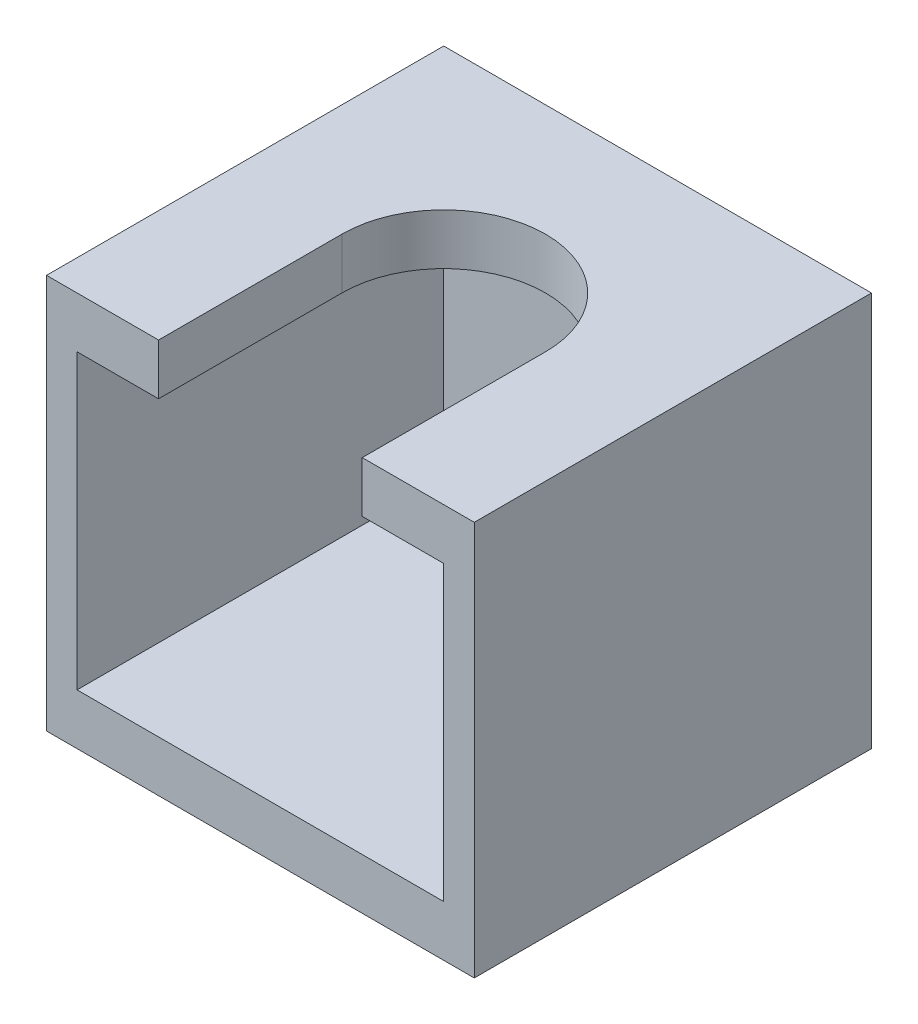
from build123d import *

# Parameters (mm, degrees)
BOSS_EXTRUDE1_DEPTH = 11.5
SKETCH2_W           = 16.8
SKETCH2_H           = 15.6
BOSS_EXTRUDE2_DEPTH = 2
BOSS_EXTRUDE3_DEPTH = 2


with BuildPart() as part:
    # Sketch1 → Boss-Extrude1 (new body)
    with BuildSketch(Plane(origin=(0, 0, 0), x_dir=(1, 0, 0), z_dir=(0, 1, 0))):
        Polygon((-8.4, 8.4), (-8.4, -7.2), (-7.2, -7.2), (-7.2, 7.2), (7.2, 7.2), (7.2, -7.2), (8.4, -7.2), (8.4, 8.4), align=None)
    extrude(amount=BOSS_EXTRUDE1_DEPTH)

    # Sketch2 → Boss-Extrude2 (add)
    with BuildSketch(Plane.XZ):
        with Locations((0, -0.6)):
            Rectangle(SKETCH2_W, SKETCH2_H)
    extrude(amount=BOSS_EXTRUDE2_DEPTH)

    # Sketch3 → Boss-Extrude3 (add)
    with BuildSketch(Plane(origin=(0, 11.5, 0), x_dir=(1, 0, 0), z_dir=(0, 1, 0))):
        with BuildLine():
            Line((-4, 0), (-4, -7.2))
            Line((-4, -7.2), (-8.4, -7.2))
            Line((-8.4, -7.2), (-8.4, 8.4))
            Line((-8.4, 8.4), (8.4, 8.4))
            Line((8.4, 8.4), (8.4, -7.2))
            Line((8.4, -7.2), (4, -7.2))
            Line((4, -7.2), (4, 0))
            ThreePointArc((4, 0), (0, 4), (-4, 0))
        make_face()
    extrude(amount=BOSS_EXTRUDE3_DEPTH)


solid = part.part
